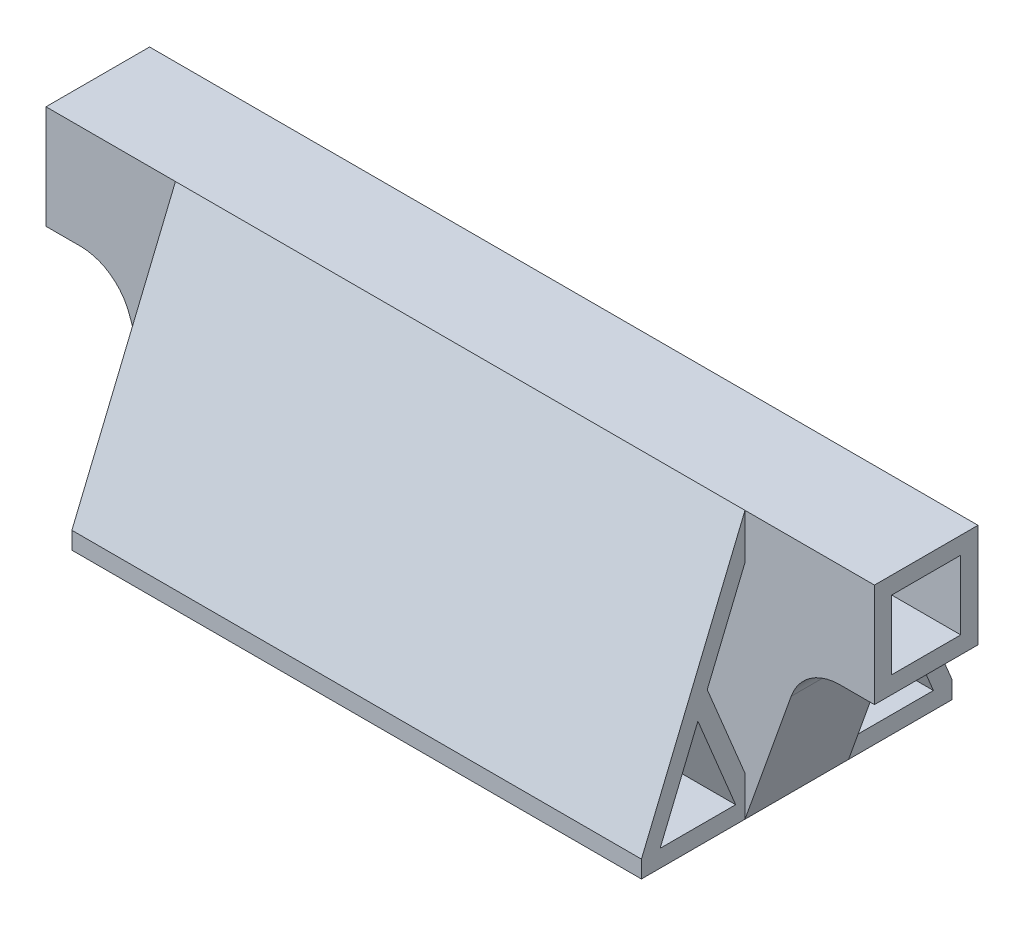
from build123d import *

# Parameters (mm, degrees)
BOSS_EXTRUDE1_DEPTH     = 28.575
CUT_EXTRUDE1_DEPTH      = 6.35
CUT_EXTRUDE1_DEPTH_BACK = 6.35
SKETCH3_W               = 12.7
SKETCH3_H               = 12.7
CUT_EXTRUDE2_DEPTH      = 77.2
CUT_EXTRUDE2_DEPTH_BACK = 77.2
CUT_EXTRUDE4_DEPTH      = 77.2
CUT_EXTRUDE4_DEPTH_BACK = 77.2
SKETCH8_W               = 23.8125
SKETCH8_H               = 19.05
CUT_EXTRUDE5_DEPTH      = 50.2125
CUT_EXTRUDE7_REACH      = 56.022
CUT_EXTRUDE11_REACH     = 22.404
SKETCH16_W              = 47.625
SKETCH16_H              = 14.99658096
FILLET9_R               = 1.5875
FILLET10_R              = 3.175


with BuildPart() as part:
    # Sketch1 → Boss-Extrude1 (new body, symmetric)
    with BuildSketch(Plane.XY):
        with BuildLine():
            Line((-52.3875, 0), (52.3875, 0))
            Line((52.3875, 0), (60.87725599, 23.833668008))
            ThreePointArc((60.87725599, 23.833668008), (64.359912354, 28.421108587), (69.85, 30.1625))
            Line((69.85, 30.1625), (76.2, 30.1625))
            Line((76.2, 30.1625), (76.2, 49.2125))
            Line((76.2, 49.2125), (-76.2, 49.2125))
            Line((-76.2, 49.2125), (-76.2, 30.1625))
            Line((-76.2, 30.1625), (-69.85, 30.1625))
            ThreePointArc((-69.85, 30.1625), (-64.359912354, 28.421108587), (-60.87725599, 23.833668008))
            Line((-60.87725599, 23.833668008), (-52.3875, 0))
        make_face()
    extrude(amount=BOSS_EXTRUDE1_DEPTH, both=True)

    # Sketch2 → Cut-Extrude1 (cut, two sides)
    with BuildSketch(Plane.XY) as cut_extrude1_sk:
        Polygon((-69.85, 33.3375), (69.85, 33.3375), (73.025, 33.3375), (73.025, 46.0375), (-73.025, 46.0375), (-73.025, 33.3375), align=None)
        with BuildLine():
            Line((-61.449739587, 30.1625), (-1.5875, 30.1625))
            Line((-1.5875, 30.1625), (-1.5875, 3.175))
            Line((-1.5875, 3.175), (-50.148046656, 3.175))
            Line((-50.148046656, 3.175), (-57.88634132, 24.899057344))
            ThreePointArc((-57.88634132, 24.899057344), (-59.333429392, 27.757313386), (-61.449739587, 30.1625))
        make_face()
        with BuildLine():
            Line((1.5875, 3.175), (1.5875, 30.1625))
            Line((1.5875, 30.1625), (61.449739587, 30.1625))
            ThreePointArc((61.449739587, 30.1625), (59.333429392, 27.757313386), (57.88634132, 24.899057344))
            Line((57.88634132, 24.899057344), (50.148046656, 3.175))
            Line((50.148046656, 3.175), (1.5875, 3.175))
        make_face()
    extrude(amount=CUT_EXTRUDE1_DEPTH, mode=Mode.SUBTRACT)
    extrude(cut_extrude1_sk.sketch, amount=-CUT_EXTRUDE1_DEPTH_BACK, mode=Mode.SUBTRACT)

    # Sketch3 → Cut-Extrude2 (cut, two sides)
    with BuildSketch(Plane(origin=(0, 0, 0), x_dir=(0, 0, -1), z_dir=(1, 0, 0))) as cut_extrude2_sk:
        with Locations((0, 39.6875)):
            Rectangle(SKETCH3_W, SKETCH3_H)
    extrude(amount=CUT_EXTRUDE2_DEPTH, mode=Mode.SUBTRACT)
    extrude(cut_extrude2_sk.sketch, amount=-CUT_EXTRUDE2_DEPTH_BACK, mode=Mode.SUBTRACT)

    # Sketch6 → Cut-Extrude4 (cut, two sides)
    with BuildSketch(Plane(origin=(0, 0, 0), x_dir=(0, 0, -1), z_dir=(1, 0, 0))) as cut_extrude4_sk:
        Polygon((28.575, 49.2125), (9.525, 49.2125), (28.575, 3.175), align=None)
        Polygon((9.525, 40.908628904), (9.525, 7.326935548), (16.472936557, 24.117782226), align=None)
        Polygon((11.243042296, 3.175), (25.138915409, 3.175), (18.190978852, 19.965846678), align=None)
        Polygon((-9.525, 49.2125), (-28.575, 3.175), (-28.575, 49.2125), align=None)
        Polygon((-25.138915409, 3.175), (-11.243042296, 3.175), (-18.190978852, 19.965846678), align=None)
        Polygon((-9.525, 7.326935548), (-9.525, 40.908628904), (-16.472936557, 24.117782226), align=None)
    extrude(amount=CUT_EXTRUDE4_DEPTH, mode=Mode.SUBTRACT)
    extrude(cut_extrude4_sk.sketch, amount=-CUT_EXTRUDE4_DEPTH_BACK, mode=Mode.SUBTRACT)

    # Sketch8 → Cut-Extrude5 (cut, through all)
    with BuildSketch(Plane.XZ):
        with Locations((64.29375, 19.05)):
            Rectangle(SKETCH8_W, SKETCH8_H)
        with Locations((64.29375, -19.05)):
            Rectangle(SKETCH8_W, SKETCH8_H)
        with Locations((-64.29375, 19.05)):
            Rectangle(SKETCH8_W, SKETCH8_H)
        with Locations((-64.29375, -19.05)):
            Rectangle(SKETCH8_W, SKETCH8_H)
    extrude(amount=-CUT_EXTRUDE5_DEPTH, mode=Mode.SUBTRACT)

    # Sketch9 → Cut-Extrude7 (cut, up to next)
    with BuildSketch(Plane(origin=(0, 10.559695431, -25.519263959), x_dir=(-1, 0, 0), z_dir=(0, 0.382351793, -0.924016832)), mode=Mode.PRIVATE) as cut_extrude7_sk1:
        Polygon((-47.625, -5.090655931), (-47.625, 3.856812854), (-42.107659634, -5.090655931), align=None)
    cut_extrude7_tool1 = extrude(cut_extrude7_sk1.sketch, amount=-CUT_EXTRUDE7_REACH, mode=Mode.PRIVATE) & part.part
    add(cut_extrude7_tool1.solids().sort_by_distance((45.785887, 8.611714, -26.325325))[0], mode=Mode.SUBTRACT)
    # Sketch9 → Cut-Extrude7 (cut, up to next)
    with BuildSketch(Plane(origin=(0, 10.559695431, -25.519263959), x_dir=(-1, 0, 0), z_dir=(0, 0.382351793, -0.924016832)), mode=Mode.PRIVATE) as cut_extrude7_sk2:
        Polygon((-47.625, 9.905925029), (-38.377553211, -5.090655931), (-29.130106422, 9.905925029), align=None)
    cut_extrude7_tool2 = extrude(cut_extrude7_sk2.sketch, amount=-CUT_EXTRUDE7_REACH, mode=Mode.PRIVATE) & part.part
    add(cut_extrude7_tool2.solids().sort_by_distance((38.377553, 15.093906, -23.643039))[0], mode=Mode.SUBTRACT)
    # Sketch9 → Cut-Extrude7 (cut, up to next)
    with BuildSketch(Plane(origin=(0, 10.559695431, -25.519263959), x_dir=(-1, 0, 0), z_dir=(0, 0.382351793, -0.924016832)), mode=Mode.PRIVATE) as cut_extrude7_sk3:
        Polygon((-34.647446789, -5.090655931), (-25.4, 9.905925029), (-16.152553211, -5.090655931), align=None)
    cut_extrude7_tool3 = extrude(cut_extrude7_sk3.sketch, amount=-CUT_EXTRUDE7_REACH, mode=Mode.PRIVATE) & part.part
    add(cut_extrude7_tool3.solids().sort_by_distance((25.4, 10.474875, -25.554362))[0], mode=Mode.SUBTRACT)
    # Sketch9 → Cut-Extrude7 (cut, up to next)
    with BuildSketch(Plane(origin=(0, 10.559695431, -25.519263959), x_dir=(-1, 0, 0), z_dir=(0, 0.382351793, -0.924016832)), mode=Mode.PRIVATE) as cut_extrude7_sk4:
        Polygon((-3.175, 9.905925029), (-12.422446789, -5.090655931), (-21.669893578, 9.905925029), align=None)
    cut_extrude7_tool4 = extrude(cut_extrude7_sk4.sketch, amount=-CUT_EXTRUDE7_REACH, mode=Mode.PRIVATE) & part.part
    add(cut_extrude7_tool4.solids().sort_by_distance((12.422447, 15.093906, -23.643039))[0], mode=Mode.SUBTRACT)
    # Sketch9 → Cut-Extrude7 (cut, up to next)
    with BuildSketch(Plane(origin=(0, 10.559695431, -25.519263959), x_dir=(-1, 0, 0), z_dir=(0, 0.382351793, -0.924016832)), mode=Mode.PRIVATE) as cut_extrude7_sk5:
        Polygon((-3.175, -5.090655931), (-3.175, 3.856812854), (-8.692340366, -5.090655931), align=None)
    cut_extrude7_tool5 = extrude(cut_extrude7_sk5.sketch, amount=-CUT_EXTRUDE7_REACH, mode=Mode.PRIVATE) & part.part
    add(cut_extrude7_tool5.solids().sort_by_distance((5.014113, 8.611714, -26.325325))[0], mode=Mode.SUBTRACT)
    # Sketch9 → Cut-Extrude7 (cut, up to next)
    with BuildSketch(Plane(origin=(0, 10.559695431, -25.519263959), x_dir=(-1, 0, 0), z_dir=(0, 0.382351793, -0.924016832)), mode=Mode.PRIVATE) as cut_extrude7_sk6:
        Polygon((47.625, 3.856812854), (42.107659634, -5.090655931), (47.625, -5.090655931), align=None)
    cut_extrude7_tool6 = extrude(cut_extrude7_sk6.sketch, amount=-CUT_EXTRUDE7_REACH, mode=Mode.PRIVATE) & part.part
    add(cut_extrude7_tool6.solids().sort_by_distance((-45.785887, 8.611714, -26.325325))[0], mode=Mode.SUBTRACT)
    # Sketch9 → Cut-Extrude7 (cut, up to next)
    with BuildSketch(Plane(origin=(0, 10.559695431, -25.519263959), x_dir=(-1, 0, 0), z_dir=(0, 0.382351793, -0.924016832)), mode=Mode.PRIVATE) as cut_extrude7_sk7:
        Polygon((38.377553211, -5.090655931), (29.130106422, 9.905925029), (47.625, 9.905925029), align=None)
    cut_extrude7_tool7 = extrude(cut_extrude7_sk7.sketch, amount=-CUT_EXTRUDE7_REACH, mode=Mode.PRIVATE) & part.part
    add(cut_extrude7_tool7.solids().sort_by_distance((-38.377553, 15.093906, -23.643039))[0], mode=Mode.SUBTRACT)
    # Sketch9 → Cut-Extrude7 (cut, up to next)
    with BuildSketch(Plane(origin=(0, 10.559695431, -25.519263959), x_dir=(-1, 0, 0), z_dir=(0, 0.382351793, -0.924016832)), mode=Mode.PRIVATE) as cut_extrude7_sk8:
        Polygon((25.4, 9.905925029), (16.152553211, -5.090655931), (34.647446789, -5.090655931), align=None)
    cut_extrude7_tool8 = extrude(cut_extrude7_sk8.sketch, amount=-CUT_EXTRUDE7_REACH, mode=Mode.PRIVATE) & part.part
    add(cut_extrude7_tool8.solids().sort_by_distance((-25.4, 10.474875, -25.554362))[0], mode=Mode.SUBTRACT)
    # Sketch9 → Cut-Extrude7 (cut, up to next)
    with BuildSketch(Plane(origin=(0, 10.559695431, -25.519263959), x_dir=(-1, 0, 0), z_dir=(0, 0.382351793, -0.924016832)), mode=Mode.PRIVATE) as cut_extrude7_sk9:
        Polygon((12.422446789, -5.090655931), (21.669893578, 9.905925029), (3.175, 9.905925029), align=None)
    cut_extrude7_tool9 = extrude(cut_extrude7_sk9.sketch, amount=-CUT_EXTRUDE7_REACH, mode=Mode.PRIVATE) & part.part
    add(cut_extrude7_tool9.solids().sort_by_distance((-12.422447, 15.093906, -23.643039))[0], mode=Mode.SUBTRACT)
    # Sketch9 → Cut-Extrude7 (cut, up to next)
    with BuildSketch(Plane(origin=(0, 10.559695431, -25.519263959), x_dir=(-1, 0, 0), z_dir=(0, 0.382351793, -0.924016832)), mode=Mode.PRIVATE) as cut_extrude7_sk10:
        Polygon((3.175, 3.856812854), (8.692340366, -5.090655931), (3.175, -5.090655931), align=None)
    cut_extrude7_tool10 = extrude(cut_extrude7_sk10.sketch, amount=-CUT_EXTRUDE7_REACH, mode=Mode.PRIVATE) & part.part
    add(cut_extrude7_tool10.solids().sort_by_distance((-5.014113, 8.611714, -26.325325))[0], mode=Mode.SUBTRACT)
    # Sketch9 → Cut-Extrude7 (cut, up to next)
    with BuildSketch(Plane(origin=(0, 10.559695431, -25.519263959), x_dir=(-1, 0, 0), z_dir=(0, 0.382351793, -0.924016832)), mode=Mode.PRIVATE) as cut_extrude7_sk11:
        Polygon((47.625, 32.570860873), (47.625, 23.623392088), (42.107659634, 32.570860873), align=None)
    cut_extrude7_tool11 = extrude(cut_extrude7_sk11.sketch, amount=-CUT_EXTRUDE7_REACH, mode=Mode.PRIVATE) & part.part
    add(cut_extrude7_tool11.solids().sort_by_distance((-45.785887, 37.899849, -14.206097))[0], mode=Mode.SUBTRACT)
    # Sketch9 → Cut-Extrude7 (cut, up to next)
    with BuildSketch(Plane(origin=(0, 10.559695431, -25.519263959), x_dir=(-1, 0, 0), z_dir=(0, 0.382351793, -0.924016832)), mode=Mode.PRIVATE) as cut_extrude7_sk12:
        Polygon((47.625, 17.574279914), (38.377553211, 32.570860873), (29.130106422, 17.574279914), align=None)
    cut_extrude7_tool12 = extrude(cut_extrude7_sk12.sketch, amount=-CUT_EXTRUDE7_REACH, mode=Mode.PRIVATE) & part.part
    add(cut_extrude7_tool12.solids().sort_by_distance((-38.377553, 31.417657, -16.888383))[0], mode=Mode.SUBTRACT)
    # Sketch9 → Cut-Extrude7 (cut, up to next)
    with BuildSketch(Plane(origin=(0, 10.559695431, -25.519263959), x_dir=(-1, 0, 0), z_dir=(0, 0.382351793, -0.924016832)), mode=Mode.PRIVATE) as cut_extrude7_sk13:
        Polygon((34.647446789, 32.570860873), (25.4, 17.574279914), (16.152553211, 32.570860873), align=None)
    cut_extrude7_tool13 = extrude(cut_extrude7_sk13.sketch, amount=-CUT_EXTRUDE7_REACH, mode=Mode.PRIVATE) & part.part
    add(cut_extrude7_tool13.solids().sort_by_distance((-25.4, 36.036688, -14.97706))[0], mode=Mode.SUBTRACT)
    # Sketch9 → Cut-Extrude7 (cut, up to next)
    with BuildSketch(Plane(origin=(0, 10.559695431, -25.519263959), x_dir=(-1, 0, 0), z_dir=(0, 0.382351793, -0.924016832)), mode=Mode.PRIVATE) as cut_extrude7_sk14:
        Polygon((3.175, 17.574279914), (12.422446789, 32.570860873), (21.669893578, 17.574279914), align=None)
    cut_extrude7_tool14 = extrude(cut_extrude7_sk14.sketch, amount=-CUT_EXTRUDE7_REACH, mode=Mode.PRIVATE) & part.part
    add(cut_extrude7_tool14.solids().sort_by_distance((-12.422447, 31.417657, -16.888383))[0], mode=Mode.SUBTRACT)
    # Sketch9 → Cut-Extrude7 (cut, up to next)
    with BuildSketch(Plane(origin=(0, 10.559695431, -25.519263959), x_dir=(-1, 0, 0), z_dir=(0, 0.382351793, -0.924016832)), mode=Mode.PRIVATE) as cut_extrude7_sk15:
        Polygon((-3.175, 23.623392088), (-8.692340366, 32.570860873), (-3.175, 32.570860873), align=None)
    cut_extrude7_tool15 = extrude(cut_extrude7_sk15.sketch, amount=-CUT_EXTRUDE7_REACH, mode=Mode.PRIVATE) & part.part
    add(cut_extrude7_tool15.solids().sort_by_distance((5.014113, 37.899849, -14.206097))[0], mode=Mode.SUBTRACT)
    # Sketch9 → Cut-Extrude7 (cut, up to next)
    with BuildSketch(Plane(origin=(0, 10.559695431, -25.519263959), x_dir=(-1, 0, 0), z_dir=(0, 0.382351793, -0.924016832)), mode=Mode.PRIVATE) as cut_extrude7_sk16:
        Polygon((3.175, 32.570860873), (3.175, 23.623392088), (8.692340366, 32.570860873), align=None)
    cut_extrude7_tool16 = extrude(cut_extrude7_sk16.sketch, amount=-CUT_EXTRUDE7_REACH, mode=Mode.PRIVATE) & part.part
    add(cut_extrude7_tool16.solids().sort_by_distance((-5.014113, 37.899849, -14.206097))[0], mode=Mode.SUBTRACT)
    # Sketch9 → Cut-Extrude7 (cut, up to next)
    with BuildSketch(Plane(origin=(0, 10.559695431, -25.519263959), x_dir=(-1, 0, 0), z_dir=(0, 0.382351793, -0.924016832)), mode=Mode.PRIVATE) as cut_extrude7_sk17:
        Polygon((-12.422446789, 32.570860873), (-21.669893578, 17.574279914), (-3.175, 17.574279914), align=None)
    cut_extrude7_tool17 = extrude(cut_extrude7_sk17.sketch, amount=-CUT_EXTRUDE7_REACH, mode=Mode.PRIVATE) & part.part
    add(cut_extrude7_tool17.solids().sort_by_distance((12.422447, 31.417657, -16.888383))[0], mode=Mode.SUBTRACT)
    # Sketch9 → Cut-Extrude7 (cut, up to next)
    with BuildSketch(Plane(origin=(0, 10.559695431, -25.519263959), x_dir=(-1, 0, 0), z_dir=(0, 0.382351793, -0.924016832)), mode=Mode.PRIVATE) as cut_extrude7_sk18:
        Polygon((-25.4, 17.574279914), (-16.152553211, 32.570860873), (-34.647446789, 32.570860873), align=None)
    cut_extrude7_tool18 = extrude(cut_extrude7_sk18.sketch, amount=-CUT_EXTRUDE7_REACH, mode=Mode.PRIVATE) & part.part
    add(cut_extrude7_tool18.solids().sort_by_distance((25.4, 36.036688, -14.97706))[0], mode=Mode.SUBTRACT)
    # Sketch9 → Cut-Extrude7 (cut, up to next)
    with BuildSketch(Plane(origin=(0, 10.559695431, -25.519263959), x_dir=(-1, 0, 0), z_dir=(0, 0.382351793, -0.924016832)), mode=Mode.PRIVATE) as cut_extrude7_sk19:
        Polygon((-38.377553211, 32.570860873), (-29.130106422, 17.574279914), (-47.625, 17.574279914), align=None)
    cut_extrude7_tool19 = extrude(cut_extrude7_sk19.sketch, amount=-CUT_EXTRUDE7_REACH, mode=Mode.PRIVATE) & part.part
    add(cut_extrude7_tool19.solids().sort_by_distance((38.377553, 31.417657, -16.888383))[0], mode=Mode.SUBTRACT)
    # Sketch9 → Cut-Extrude7 (cut, up to next)
    with BuildSketch(Plane(origin=(0, 10.559695431, -25.519263959), x_dir=(-1, 0, 0), z_dir=(0, 0.382351793, -0.924016832)), mode=Mode.PRIVATE) as cut_extrude7_sk20:
        Polygon((-47.625, 23.623392088), (-42.107659634, 32.570860873), (-47.625, 32.570860873), align=None)
    cut_extrude7_tool20 = extrude(cut_extrude7_sk20.sketch, amount=-CUT_EXTRUDE7_REACH, mode=Mode.PRIVATE) & part.part
    add(cut_extrude7_tool20.solids().sort_by_distance((45.785887, 37.899849, -14.206097))[0], mode=Mode.SUBTRACT)

    # Sketch16 → Cut-Extrude11 (cut, up to next)
    with BuildSketch(Plane(origin=(0, -2.294031757, -5.543910081), x_dir=(1, 0, 0), z_dir=(0, 0.382351793, 0.924016832)), mode=Mode.PRIVATE) as cut_extrude11_sk1:
        with Locations((-25.4, 16.3183413)):
            Rectangle(SKETCH16_W, SKETCH16_H)
    cut_extrude11_tool1 = extrude(cut_extrude11_sk1.sketch, amount=-CUT_EXTRUDE11_REACH, mode=Mode.PRIVATE) & part.part
    add(cut_extrude11_tool1.solids().sort_by_distance((-25.4, 12.78439, -11.783257))[0], mode=Mode.SUBTRACT)
    # Sketch16 → Cut-Extrude11 (cut, up to next)
    with BuildSketch(Plane(origin=(0, -2.294031757, -5.543910081), x_dir=(1, 0, 0), z_dir=(0, 0.382351793, 0.924016832)), mode=Mode.PRIVATE) as cut_extrude11_sk2:
        with Locations((25.4, 16.3183413)):
            Rectangle(SKETCH16_W, SKETCH16_H)
    cut_extrude11_tool2 = extrude(cut_extrude11_sk2.sketch, amount=-CUT_EXTRUDE11_REACH, mode=Mode.PRIVATE) & part.part
    add(cut_extrude11_tool2.solids().sort_by_distance((25.4, 12.78439, -11.783257))[0], mode=Mode.SUBTRACT)

    # Fillet9
    fillet9_edges = [part.edges().sort_by_distance(p)[0] for p in [
        (-42.107659634, 40.048735654, -11.598860192),
        (-47.625, 40.048735654, -11.598860192),
        (-47.625, 31.781123889, -15.019940923),
        (-8.692340366, 5.248860192, -25.998808659),
        (-3.175, 13.516471957, -22.577727929),
        (-3.175, 5.248860192, -25.998808659),
        (-3.175, 40.048735654, -11.598860192),
        (-8.692340366, 40.048735654, -11.598860192),
        (-3.175, 31.781123889, -15.019940923),
        (8.692340366, 40.048735654, -11.598860192),
        (3.175, 31.781123889, -15.019940923),
        (3.175, 40.048735654, -11.598860192),
        (-47.625, 13.516471957, -22.577727929),
        (-47.625, 5.248860192, -25.998808659),
        (-42.107659634, 5.248860192, -25.998808659),
        (3.175, 5.248860192, -25.998808659),
        (8.692340366, 5.248860192, -25.998808659),
        (3.175, 13.516471957, -22.577727929),
        (42.107659634, 5.248860192, -25.998808659),
        (47.625, 5.248860192, -25.998808659),
        (47.625, 13.516471957, -22.577727929),
        (47.625, 31.781123889, -15.019940923),
        (47.625, 40.048735654, -11.598860192),
        (42.107659634, 40.048735654, -11.598860192),
    ]]
    fillet(fillet9_edges, radius=FILLET9_R)

    # Fillet10
    fillet10_edges = [part.edges().sort_by_distance(p)[0] for p in [
        (-47.625, 26.191642419, -17.332829807),
        (-29.130106422, 26.191642419, -17.332829807),
        (-38.377553211, 40.048735654, -11.598860192),
        (-16.152553211, 40.048735654, -11.598860192),
        (-34.647446789, 40.048735654, -11.598860192),
        (-25.4, 26.191642419, -17.332829807),
        (12.422446789, 40.048735654, -11.598860192),
        (3.175, 26.191642419, -17.332829807),
        (21.669893578, 26.191642419, -17.332829807),
        (-21.669893578, 26.191642419, -17.332829807),
        (-3.175, 26.191642419, -17.332829807),
        (-12.422446789, 40.048735654, -11.598860192),
        (-47.625, 19.105953428, -20.264839045),
        (-38.377553211, 5.248860192, -25.998808659),
        (-29.130106422, 19.105953428, -20.264839045),
        (-12.422446789, 5.248860192, -25.998808659),
        (-3.175, 19.105953428, -20.264839045),
        (-21.669893578, 19.105953428, -20.264839045),
        (-25.4, 19.105953428, -20.264839045),
        (-34.647446789, 5.248860192, -25.998808659),
        (-16.152553211, 5.248860192, -25.998808659),
        (21.669893578, 19.105953428, -20.264839045),
        (3.175, 19.105953428, -20.264839045),
        (12.422446789, 5.248860192, -25.998808659),
        (25.4, 19.105953428, -20.264839045),
        (16.152553211, 5.248860192, -25.998808659),
        (34.647446789, 5.248860192, -25.998808659),
        (25.4, 26.191642419, -17.332829807),
        (34.647446789, 40.048735654, -11.598860192),
        (16.152553211, 40.048735654, -11.598860192),
        (47.625, 26.191642419, -17.332829807),
        (38.377553211, 40.048735654, -11.598860192),
        (29.130106422, 26.191642419, -17.332829807),
        (47.625, 19.105953428, -20.264839045),
        (29.130106422, 19.105953428, -20.264839045),
        (38.377553211, 5.248860192, -25.998808659),
    ]]
    fillet(fillet10_edges, radius=FILLET10_R)


solid = part.part
